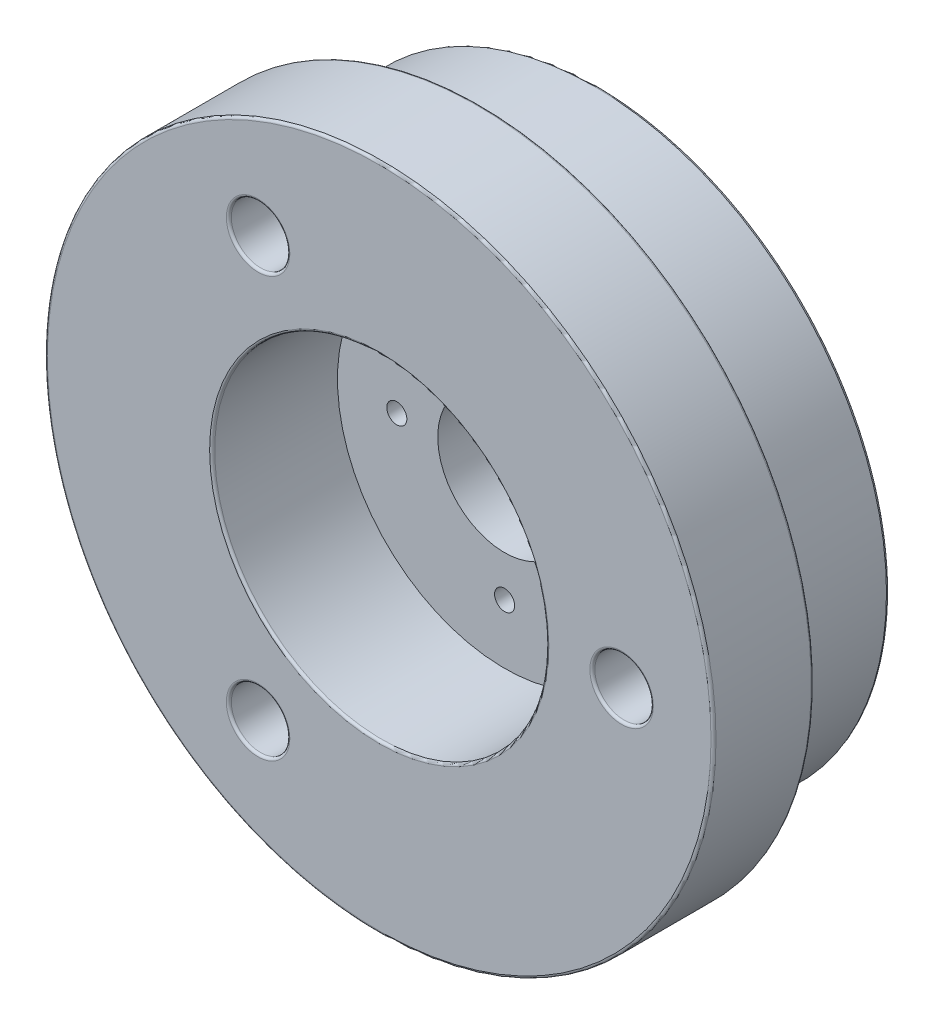
from build123d import *

# Parameters (mm, degrees)
SZKIC2_R                   = 1.75
SZKIC2_R_2                 = 4
SZKIC2_R_3                 = 0.6
WYTNIJ_WYCI_GNI_CIE1_DEPTH = 32.128764833
SZKIC2_4_R                 = 10
SZKIC2_4_R_2               = 4
SZKIC2_4_R_3               = 0.6
SZKIC2_4_R_4               = 1.75
WYTNIJ_WYCI_GNI_CIE3_DEPTH = 7.5
ZAOKR_GLENIE1_R            = 0.15


with BuildPart() as part:
    # Szkic1 → Obr_t1 (revolve)
    with BuildSketch(Plane(origin=(0, 0, 0), x_dir=(1, 0, 0), z_dir=(0, 1, 0))):
        Polygon((0, 0), (-20, 0), (-20, 6), (-17.5, 6), (-17.5, 13), (0, 13), align=None)
    revolve(axis=Axis((0, 0, -13), (0, 0, 1)))

    # Szkic2 → Wytnij-wyci_gni_cie1 (cut, through all)
    with BuildSketch(Plane.XY):
        with Locations((14.5, 0)):
            Circle(SZKIC2_R)
        with Locations((-7.25, -12.557368355)):
            Circle(SZKIC2_R)
        with Locations((-7.25, 12.557368355)):
            Circle(SZKIC2_R)
        Circle(SZKIC2_R_2)
        with Locations((6.45, 0)):
            Circle(SZKIC2_R_3)
        with Locations((0, -6.45)):
            Circle(SZKIC2_R_3)
        with Locations((-6.45, 0)):
            Circle(SZKIC2_R_3)
        with Locations((0, 6.45)):
            Circle(SZKIC2_R_3)
    extrude(amount=-WYTNIJ_WYCI_GNI_CIE1_DEPTH, mode=Mode.SUBTRACT)

    # Szkic2_4 → Wytnij-wyci_gni_cie3 (cut)
    # profile 1 of 4: a face of its own
    with BuildSketch(Plane.XY):
        Circle(SZKIC2_4_R)
        Circle(SZKIC2_4_R_2, mode=Mode.SUBTRACT)
        with Locations((6.45, 0)):
            Circle(SZKIC2_4_R_3, mode=Mode.SUBTRACT)
        with Locations((0, -6.45)):
            Circle(SZKIC2_4_R_3, mode=Mode.SUBTRACT)
        with Locations((-6.45, 0)):
            Circle(SZKIC2_4_R_3, mode=Mode.SUBTRACT)
        with Locations((0, 6.45)):
            Circle(SZKIC2_4_R_3, mode=Mode.SUBTRACT)
    # profile 2 of 4: a face of its own
    with BuildSketch(Plane.XY):
        with Locations((14.5, 0)):
            Circle(SZKIC2_4_R_4)
    # profile 3 of 4: a face of its own
    with BuildSketch(Plane.XY):
        with Locations((-7.25, -12.557368355)):
            Circle(SZKIC2_4_R_4)
    # profile 4 of 4: a face of its own
    with BuildSketch(Plane.XY):
        with Locations((-7.25, 12.557368355)):
            Circle(SZKIC2_4_R_4)
    extrude(amount=-WYTNIJ_WYCI_GNI_CIE3_DEPTH, mode=Mode.SUBTRACT)

    # Zaokr_glenie1
    zaokr_glenie1_edges = [part.edges().sort_by_distance(p)[0] for p in [
        (17.5, 0, -6),
        (20, 0, -6),
        (17.5, 0, -13),
        (-7.05, 0, -13),
        (12.75, 0, -13),
        (-9, -12.557368355, -13),
        (-9, 12.557368355, -13),
        (-4, 0, -13),
        (-0.6, -6.45, -13),
        (5.85, 0, -13),
        (-0.6, 6.45, -13),
        (20, 0, 0),
        (12.75, 0, 0),
        (-9, -12.557368355, 0),
        (-9, 12.557368355, 0),
        (-10, 0, 0),
    ]]
    fillet(zaokr_glenie1_edges, radius=ZAOKR_GLENIE1_R)


solid = part.part
